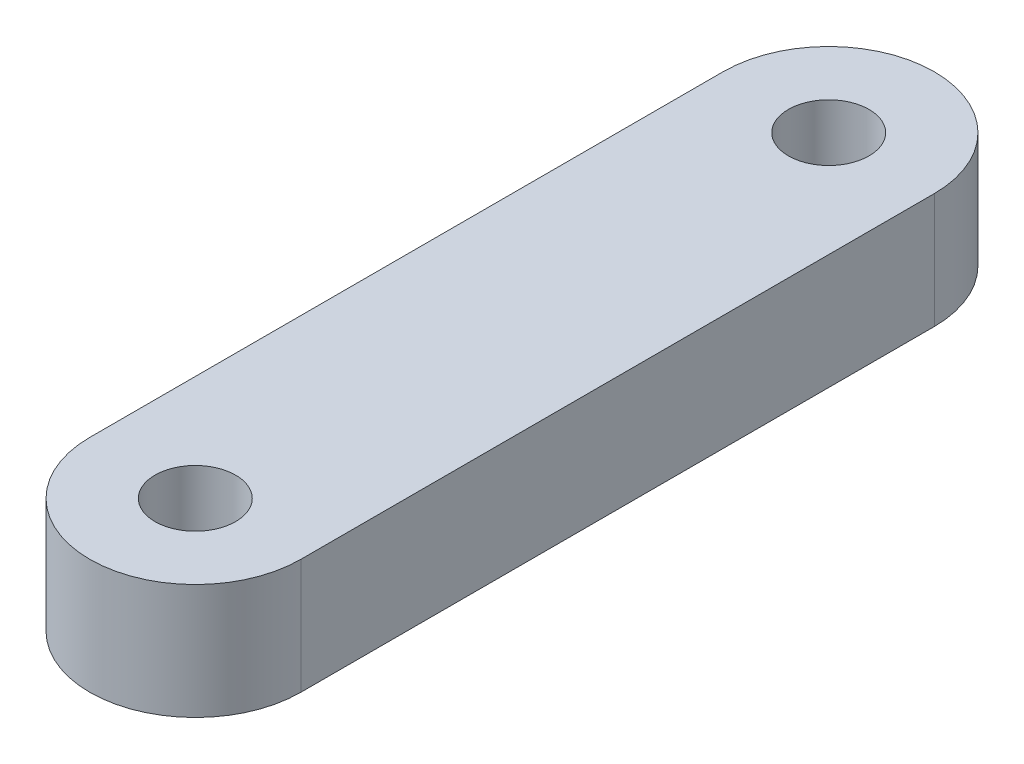
from build123d import *

# Parameters (mm, degrees)
SKETCH1_R           = 2.1
BOSS_EXTRUDE1_DEPTH = 6


with BuildPart() as part:
    # Sketch1 → Boss-Extrude1 (new body)
    with BuildSketch(Plane(origin=(0, 0, 0), x_dir=(1, 0, 0), z_dir=(0, 1, 0))):
        with BuildLine():
            Line((1.753637438, 17.723920197), (1.753637438, -15.276079803))
            ThreePointArc((1.753637438, -15.276079803), (-3.746362562, -20.776079803), (-9.246362562, -15.276079803))
            Line((-9.246362562, -15.276079803), (-9.246362562, 17.723920197))
            ThreePointArc((-9.246362562, 17.723920197), (-3.746362562, 23.223920197), (1.753637438, 17.723920197))
        make_face()
        with Locations((-3.746362562, -15.276079803)):
            Circle(SKETCH1_R, mode=Mode.SUBTRACT)
        with Locations((-3.746362562, 17.723920197)):
            Circle(SKETCH1_R, mode=Mode.SUBTRACT)
    extrude(amount=BOSS_EXTRUDE1_DEPTH)


solid = part.part
